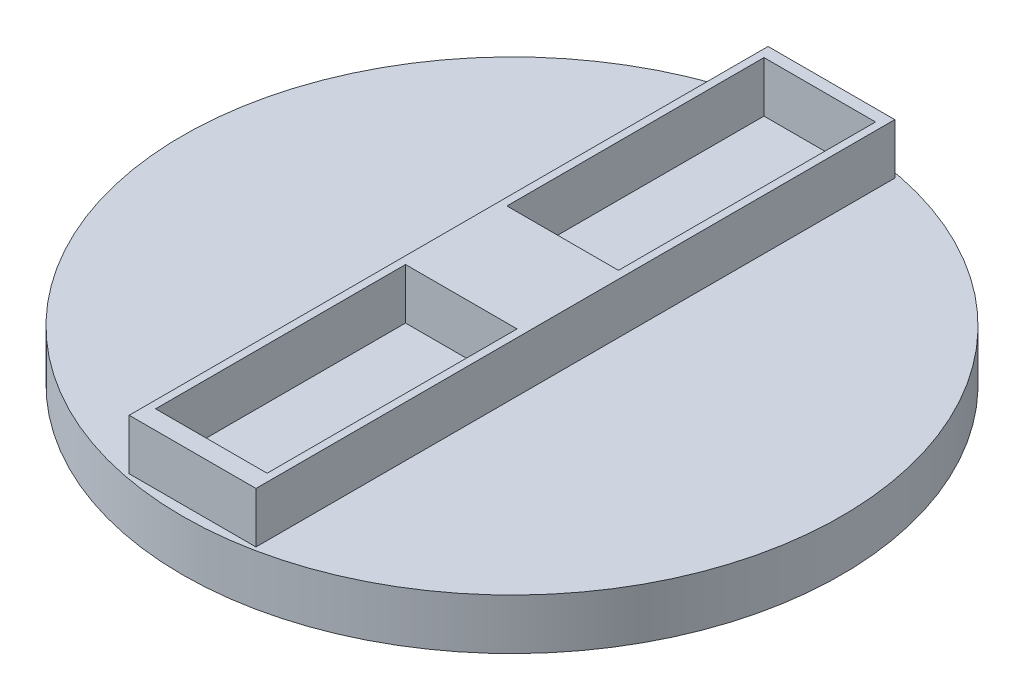
from build123d import *

# Parameters (mm, degrees)
SKETCH1_W           = 25
SKETCH1_H           = 126
SKETCH1_W_2         = 22
SKETCH1_H_2         = 50.698113208
SKETCH1_H_3         = 49.301886792
BOSS_EXTRUDE1_DEPTH = 10
SKETCH2_R           = 65
BOSS_EXTRUDE2_DEPTH = 10


with BuildPart() as part:
    # Sketch1 → Boss-Extrude1 (new body)
    with BuildSketch(Plane(origin=(0, 0, 0), x_dir=(1, 0, 0), z_dir=(0, 1, 0))):
        Rectangle(SKETCH1_W, SKETCH1_H)
        with Locations((0, 35.349056604)):
            Rectangle(SKETCH1_W_2, SKETCH1_H_2, mode=Mode.SUBTRACT)
        with Locations((0, -34.650943396)):
            Rectangle(SKETCH1_W_2, SKETCH1_H_3, mode=Mode.SUBTRACT)
    extrude(amount=BOSS_EXTRUDE1_DEPTH)

    # Sketch2 → Boss-Extrude2 (add)
    with BuildSketch(Plane(origin=(0, 0, 0), x_dir=(1, 0, 0), z_dir=(0, 1, 0))):
        Circle(SKETCH2_R)
    extrude(amount=-BOSS_EXTRUDE2_DEPTH)


solid = part.part
